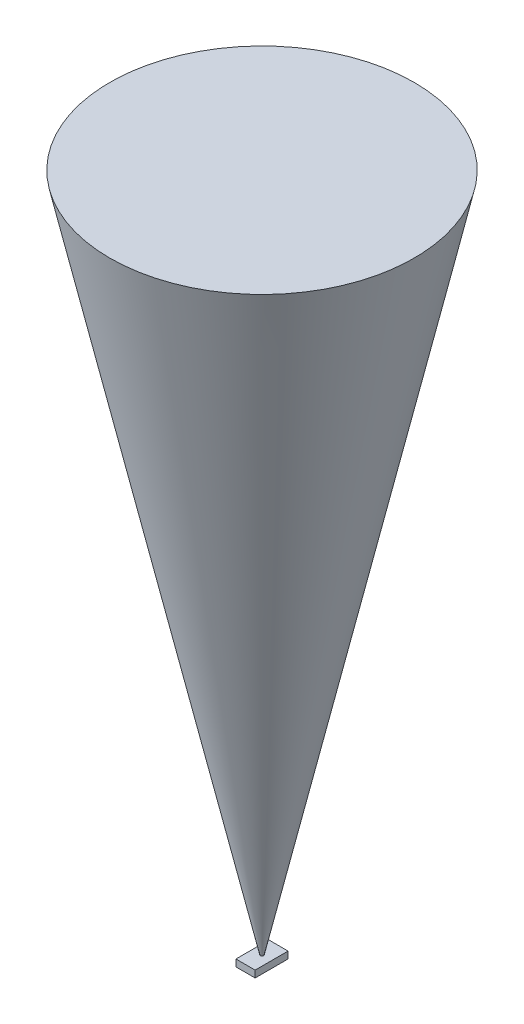
from build123d import *

# Parameters (mm, degrees)
ESQUISSE1_W        = 2.8
ESQUISSE1_H        = 4.8
BOSS_EXTRU_1_DEPTH = 1


with BuildPart() as part:
    # Esquisse1 → Boss.-Extru.1 (new body)
    with BuildSketch(Plane(origin=(0, 0, 0), x_dir=(1, 0, 0), z_dir=(0, 1, 0))):
        Rectangle(ESQUISSE1_W, ESQUISSE1_H)
    extrude(amount=BOSS_EXTRU_1_DEPTH)

    # Esquisse2 → Révolution1 (revolve)
    with BuildSketch(Plane(origin=(0, 0, 0), x_dir=(0, 0, -1), z_dir=(1, 0, 0))):
        Polygon((0, 0), (0, 100), (22.169466264, 100), align=None)
    revolve(axis=Axis((0, 0, 0), (0, 1, 0)))


solid = part.part
